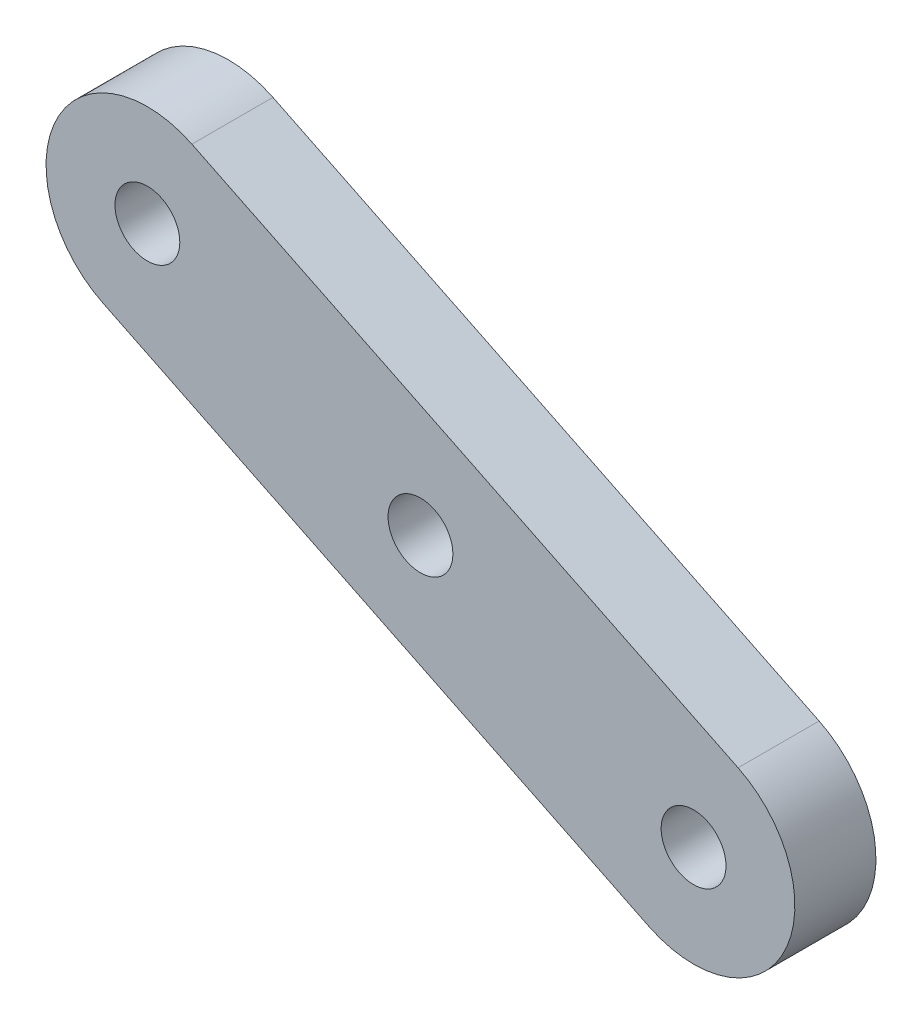
from build123d import *

# Parameters (mm, degrees)
SKETCH1_R           = 1.6
BOSS_EXTRUDE1_DEPTH = 4


with BuildPart() as part:
    # Sketch1 → Boss-Extrude1 (new body)
    with BuildSketch(Plane.XY):
        with BuildLine():
            Line((-2.195689363, -4.492098421), (-29.148279888, 8.682037755))
            ThreePointArc((-29.148279888, 8.682037755), (-31.444688946, 15.369825539), (-24.756901162, 17.666234597))
            Line((-24.756901162, 17.666234597), (2.195689363, 4.492098421))
            ThreePointArc((2.195689363, 4.492098421), (4.492098421, -2.195689363), (-2.195689363, -4.492098421))
        make_face()
        with Locations((-26.952590525, 13.174136176)):
            Circle(SKETCH1_R, mode=Mode.SUBTRACT)
        Circle(SKETCH1_R, mode=Mode.SUBTRACT)
        with Locations((-13.476295263, 6.587068088)):
            Circle(SKETCH1_R, mode=Mode.SUBTRACT)
    extrude(amount=BOSS_EXTRUDE1_DEPTH)


solid = part.part
